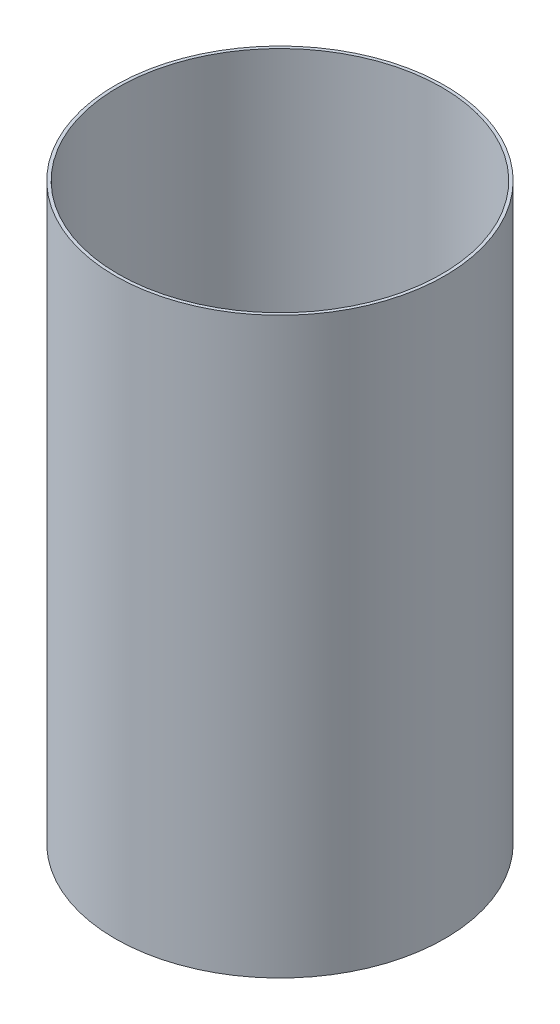
from build123d import *

# Parameters (mm, degrees)
SKETCH1_R           = 33.0835
SKETCH1_R_2         = 32.4612
BOSS_EXTRUDE1_DEPTH = 115.146666667


with BuildPart() as part:
    # Sketch1 → Boss-Extrude1 (new body)
    with BuildSketch(Plane(origin=(0, 0, 0), x_dir=(1, 0, 0), z_dir=(0, 1, 0))):
        Circle(SKETCH1_R)
        Circle(SKETCH1_R_2, mode=Mode.SUBTRACT)
    extrude(amount=BOSS_EXTRUDE1_DEPTH)


solid = part.part
